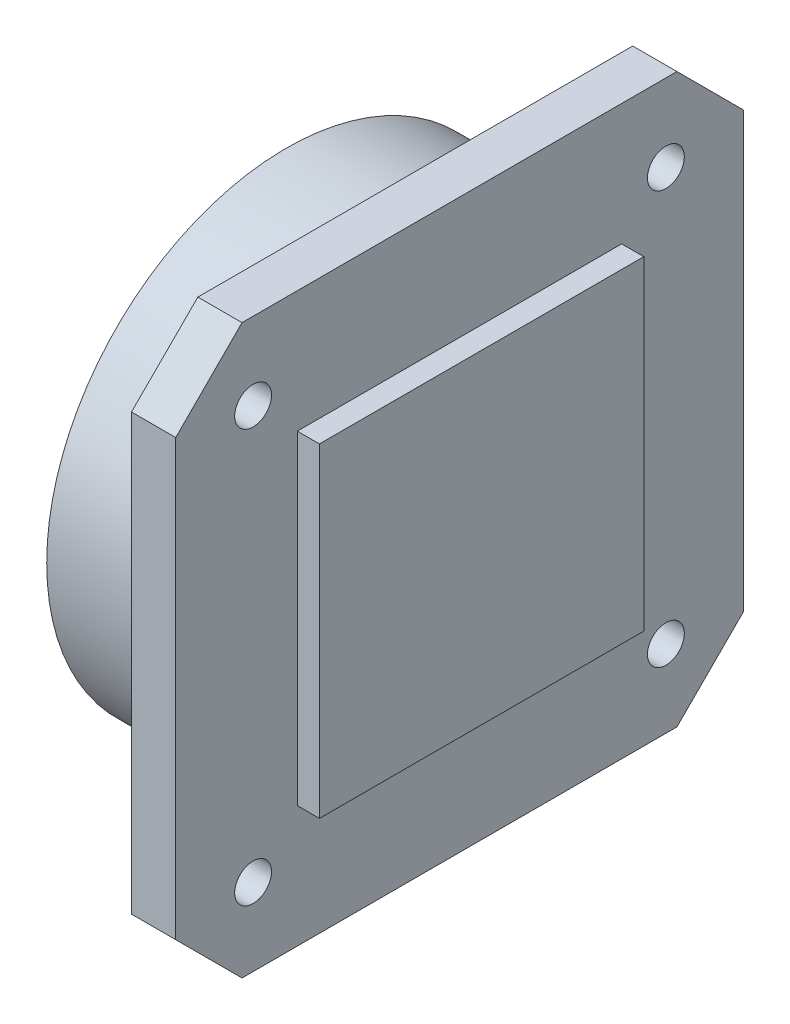
from build123d import *

# Parameters (mm, degrees)
EXTRUDE1_DEPTH            = 6
SKETCH2_W                 = 44
SKETCH2_H                 = 44
EXTRUDE2_DEPTH            = 3
SKETCH4_R                 = 32.5
EXTRUDE3_DEPTH            = 17.5
SKETCH16_R                = 21
EXTRUDE7_DEPTH            = 12
SKETCH19_R                = 2.5
EXTRUDE8_DEPTH            = 24.5
LPATTERN1_COUNT           = 2
LPATTERN1_PITCH           = 56
LPATTERN2_COUNT           = 2
LPATTERN2_PITCH           = 56
LPATTERN2_COPY_1_SKETCH_R = 2.5
LPATTERN2_COPY_1_DEPTH    = 24.5
SKETCH20_R                = 12.5
EXTRUDE10_DEPTH           = 4


with BuildPart() as part:
    # Sketch1 → Extrude1 (new body)
    with BuildSketch(Plane(origin=(0, 0, 0), x_dir=(0, 0, -1), z_dir=(1, 0, 0))):
        Polygon((0, 68), (9, 77), (68, 77), (77, 68), (77, 9), (68, 0), (9, 0), (0, 9), align=None)
    extrude(amount=EXTRUDE1_DEPTH)

    # Sketch2 → Extrude2 (add)
    with BuildSketch(Plane(origin=(6, 0, 0), x_dir=(0, 0, -1), z_dir=(1, 0, 0))):
        with Locations((38.5, 38.5)):
            Rectangle(SKETCH2_W, SKETCH2_H)
    extrude(amount=EXTRUDE2_DEPTH)

    # Sketch4 → Extrude3 (add)
    with BuildSketch(Plane.ZY):
        with Locations((-38.5, 38.5)):
            Circle(SKETCH4_R)
    extrude(amount=EXTRUDE3_DEPTH)

    # Sketch16 → Extrude7 (cut)
    with BuildSketch(Plane.ZY.offset(17.5)):
        with Locations((-38.5, 38.5)):
            Circle(SKETCH16_R)
    extrude(amount=-EXTRUDE7_DEPTH, mode=Mode.SUBTRACT)

    # Sketch18 → Revolve2 (revolve)
    with BuildSketch(Plane.XZ.offset(-38.5)):
        Polygon((-5.5, -56.5), (-5.5, -59.5), (-17.5, -59.5), align=None)
    revolve(axis=Axis((9, 38.5, -38.5), (-1, 0, 0)))

    # Sketch19 → Extrude8 (cut, through all)
    with BuildSketch(Plane(origin=(6, 0, 0), x_dir=(0, 0, -1), z_dir=(1, 0, 0))):
        with Locations((10.5, 66.5)):
            Circle(SKETCH19_R)
    extrude8 = extrude(amount=-EXTRUDE8_DEPTH, mode=Mode.SUBTRACT)

    # LPattern1: Extrude8 ×2
    with Locations(*[(0, 0, -i * LPATTERN1_PITCH) for i in range(1, LPATTERN1_COUNT)]):
        add(extrude8, mode=Mode.SUBTRACT)

    # LPattern2: Extrude8 ×2
    with Locations(*[(0, -i * LPATTERN2_PITCH, 0) for i in range(1, LPATTERN2_COUNT)]):
        add(extrude8, mode=Mode.SUBTRACT)

    # LPattern2 copy 1 sketch → LPattern2 copy 1 (cut, through all)
    with BuildSketch(Plane(origin=(6, -56, -56), x_dir=(0, 0, -1), z_dir=(1, 0, 0))):
        with Locations((10.5, 66.5)):
            Circle(LPATTERN2_COPY_1_SKETCH_R)
    extrude(amount=-LPATTERN2_COPY_1_DEPTH, mode=Mode.SUBTRACT)

    # Sketch20 → Extrude10 (cut)
    with BuildSketch(Plane.ZY.offset(5.5)):
        with Locations((-38.5, 38.5)):
            Circle(SKETCH20_R)
    extrude(amount=-EXTRUDE10_DEPTH, mode=Mode.SUBTRACT)


solid = part.part
